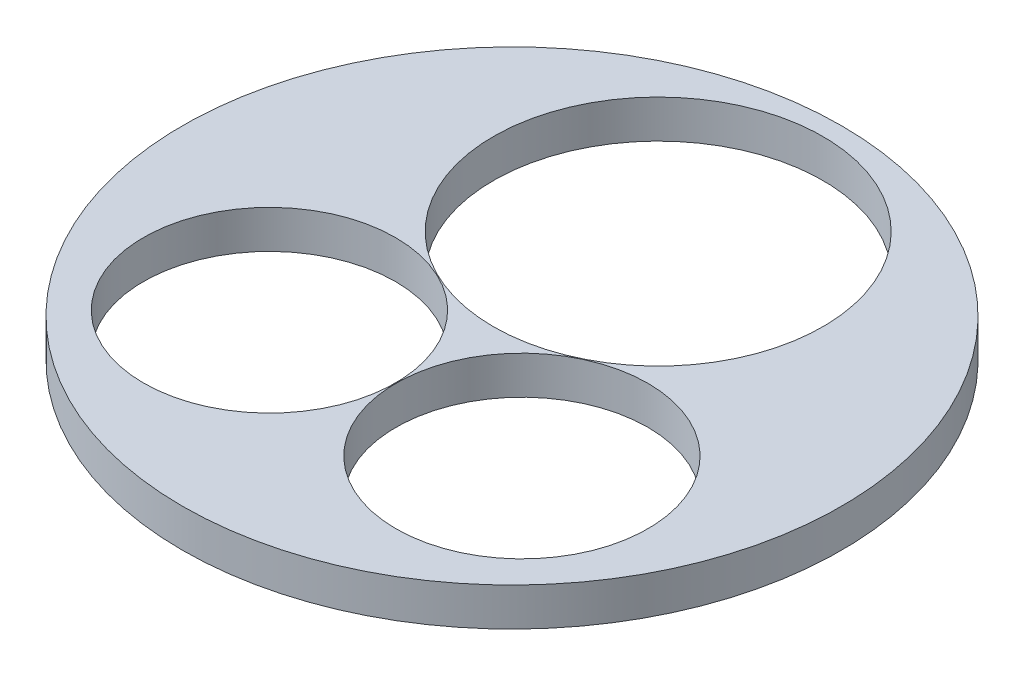
from build123d import *

# Parameters (mm, degrees)
SKETCH1_R           = 863.6
SKETCH1_R_2         = 330.2
SKETCH1_R_3         = 431.8
BOSS_EXTRUDE1_DEPTH = 100


with BuildPart() as part:
    # Sketch1 → Boss-Extrude1 (new body)
    with BuildSketch(Plane(origin=(0, 0, 0), x_dir=(1, 0, 0), z_dir=(0, 1, 0))):
        Circle(SKETCH1_R)
        with Locations((330.835, -304.8)):
            Circle(SKETCH1_R_2, mode=Mode.SUBTRACT)
        with Locations((0, 383.043947182)):
            Circle(SKETCH1_R_3, mode=Mode.SUBTRACT)
        with Locations((-330.835, -304.8)):
            Circle(SKETCH1_R_2, mode=Mode.SUBTRACT)
    extrude(amount=BOSS_EXTRUDE1_DEPTH)


solid = part.part
